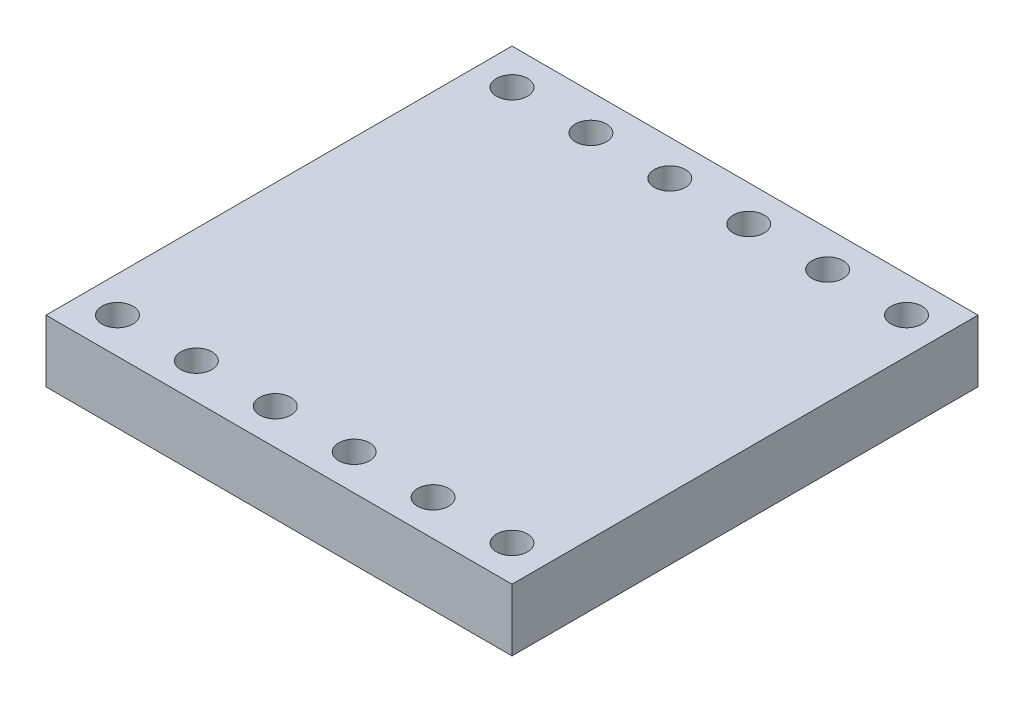
from build123d import *

# Parameters (mm, degrees)
SKETCH1_W           = 15
SKETCH1_H           = 15
BOSS_EXTRUDE1_DEPTH = 2
SKETCH3_R           = 0.5
CUT_EXTRUDE1_DEPTH  = 2


with BuildPart() as part:
    # Sketch1 → Boss-Extrude1 (new body)
    with BuildSketch(Plane(origin=(0, 0, 0), x_dir=(1, 0, 0), z_dir=(0, 1, 0))):
        with Locations((7.5, 7.5)):
            Rectangle(SKETCH1_W, SKETCH1_H)
    extrude(amount=BOSS_EXTRUDE1_DEPTH)

    # Sketch3 → Cut-Extrude1 (cut)
    with BuildSketch(Plane(origin=(0, 2, 0), x_dir=(1, 0, 0), z_dir=(0, 1, 0))):
        with Locations((13.85, 1.15)):
            Circle(SKETCH3_R)
        with Locations((11.31, 1.15)):
            Circle(SKETCH3_R)
        with Locations((8.77, 1.15)):
            Circle(SKETCH3_R)
        with Locations((6.23, 1.15)):
            Circle(SKETCH3_R)
        with Locations((3.69, 1.15)):
            Circle(SKETCH3_R)
        with Locations((1.15, 1.15)):
            Circle(SKETCH3_R)
        with Locations((13.85, 13.85)):
            Circle(SKETCH3_R)
        with Locations((11.31, 13.85)):
            Circle(SKETCH3_R)
        with Locations((8.77, 13.85)):
            Circle(SKETCH3_R)
        with Locations((6.23, 13.85)):
            Circle(SKETCH3_R)
        with Locations((3.69, 13.85)):
            Circle(SKETCH3_R)
        with Locations((1.15, 13.85)):
            Circle(SKETCH3_R)
    extrude(amount=-CUT_EXTRUDE1_DEPTH, mode=Mode.SUBTRACT)


solid = part.part
